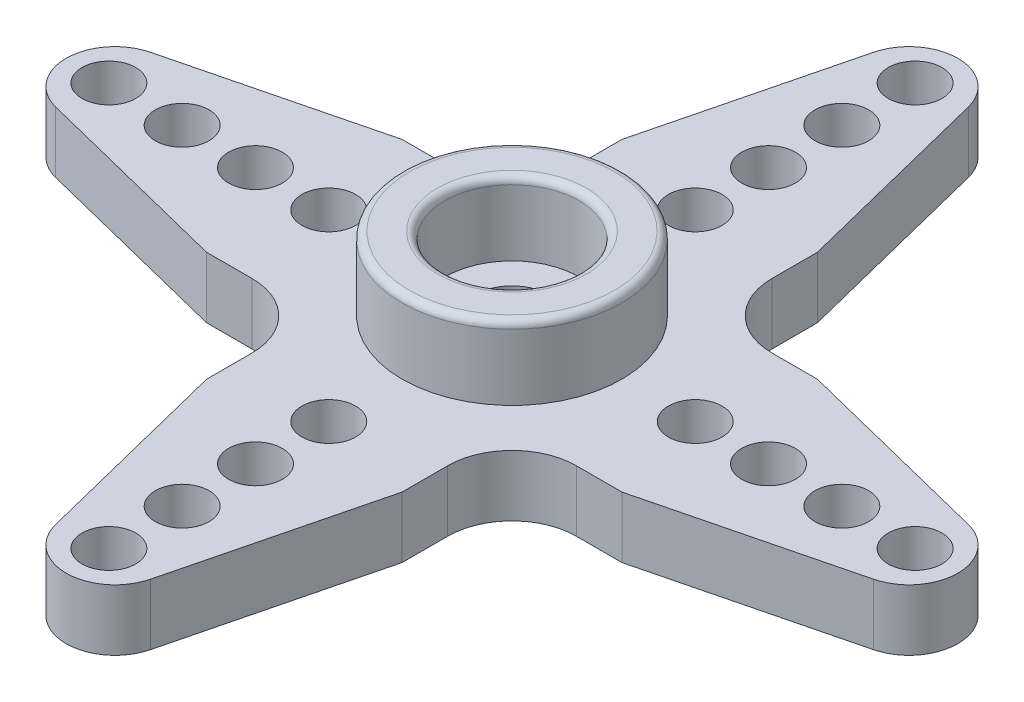
from build123d import *

# Parameters (mm, degrees)
SALIENTE_EXTRUIR1_DEPTH = 2.5
CROQUIS2_R              = 4.5
CROQUIS2_R_2            = 2.75
SALIENTE_EXTRUIR2_DEPTH = 3
CORTAR_EXTRUIR1_REACH   = 7.5
CROQUIS3_R              = 1.5
CROQUIS4_R              = 2.8
CORTAR_EXTRUIR2_DEPTH   = 1
CROQUIS5_R              = 4.5
CROQUIS5_R_2            = 3.5
CORTAR_EXTRUIR3_DEPTH   = 0.5
REDONDEO1_R             = 0.3
CROQUIS6_R              = 1.1
CORTAR_EXTRUIR4_DEPTH   = 2.5
MATRIZC1_COUNT          = 4


with BuildPart() as part:
    # Croquis1 → Saliente-Extruir1 (new body)
    with BuildSketch(Plane(origin=(0, 0, 0), x_dir=(1, 0, 0), z_dir=(0, 1, 0))):
        with BuildLine():
            Line((-8.5, 4), (-6.639087297, 4))
            ThreePointArc((-6.639087297, 4), (-4.772970773, 4.772970773), (-4, 6.639087297))
            Line((-4, 6.639087297), (-4, 8.5))
            Line((-4, 8.5), (-1.940232481, 16.73528128))
            ThreePointArc((-1.940232481, 16.73528128), (0, 18.25), (1.940232481, 16.73528128))
            Line((1.940232481, 16.73528128), (4, 8.5))
            Line((4, 8.5), (4, 6.639087297))
            ThreePointArc((4, 6.639087297), (4.772970773, 4.772970773), (6.639087297, 4))
            Line((6.639087297, 4), (8.5, 4))
            Line((8.5, 4), (16.73528128, 1.940232481))
            ThreePointArc((16.73528128, 1.940232481), (18.25, 0), (16.73528128, -1.940232481))
            Line((16.73528128, -1.940232481), (8.5, -4))
            Line((8.5, -4), (6.639087297, -4))
            ThreePointArc((6.639087297, -4), (4.772970773, -4.772970773), (4, -6.639087297))
            Line((4, -6.639087297), (4, -8.5))
            Line((4, -8.5), (1.940232481, -16.73528128))
            ThreePointArc((1.940232481, -16.73528128), (0, -18.25), (-1.940232481, -16.73528128))
            Line((-1.940232481, -16.73528128), (-4, -8.5))
            Line((-4, -8.5), (-4, -6.639087297))
            ThreePointArc((-4, -6.639087297), (-4.772970773, -4.772970773), (-6.639087297, -4))
            Line((-6.639087297, -4), (-8.5, -4))
            Line((-8.5, -4), (-16.73528128, -1.940232481))
            ThreePointArc((-16.73528128, -1.940232481), (-18.25, 0), (-16.73528128, 1.940232481))
            Line((-16.73528128, 1.940232481), (-8.5, 4))
        make_face()
    extrude(amount=SALIENTE_EXTRUIR1_DEPTH)

    # Croquis2 → Saliente-Extruir2 (add)
    with BuildSketch(Plane(origin=(0, 2.5, 0), x_dir=(1, 0, 0), z_dir=(0, 1, 0))):
        Circle(CROQUIS2_R)
        Circle(CROQUIS2_R_2, mode=Mode.SUBTRACT)
    extrude(amount=SALIENTE_EXTRUIR2_DEPTH)

    # Croquis3 → Cortar-Extruir1 (cut, up to next)
    with BuildSketch(Plane.XZ, mode=Mode.PRIVATE) as cortar_extruir1_sk1:
        Circle(CROQUIS3_R)
    cortar_extruir1_tool1 = extrude(cortar_extruir1_sk1.sketch, amount=-CORTAR_EXTRUIR1_REACH, mode=Mode.PRIVATE) & part.part
    add(cortar_extruir1_tool1.solids().sort_by_distance((0, 0, 0))[0], mode=Mode.SUBTRACT)

    # Croquis4 → Cortar-Extruir2 (cut)
    with BuildSketch(Plane.XZ):
        Circle(CROQUIS4_R)
    extrude(amount=-CORTAR_EXTRUIR2_DEPTH, mode=Mode.SUBTRACT)

    # Croquis5 → Cortar-Extruir3 (cut)
    with BuildSketch(Plane.XZ):
        Circle(CROQUIS5_R)
        Circle(CROQUIS5_R_2, mode=Mode.SUBTRACT)
    extrude(amount=-CORTAR_EXTRUIR3_DEPTH, mode=Mode.SUBTRACT)

    # Redondeo1
    redondeo1_edges = [part.edges().sort_by_distance(p)[0] for p in [
        (-4.5, 5.5, 0),
        (-2.75, 5.5, 0),
        (-2.8, 0, 0),
        (-4.5, 0, 0),
        (-3.5, 0, 0),
    ]]
    fillet(redondeo1_edges, radius=REDONDEO1_R)

    # Croquis6 → Cortar-Extruir4 (cut)
    with BuildSketch(Plane.XZ):
        with Locations((0, -16.5)):
            Circle(CROQUIS6_R)
        with Locations((0, -13.5)):
            Circle(CROQUIS6_R)
        with Locations((0, -10.5)):
            Circle(CROQUIS6_R)
        with Locations((0, -7.5)):
            Circle(CROQUIS6_R)
    cortar_extruir4 = extrude(amount=-CORTAR_EXTRUIR4_DEPTH, mode=Mode.SUBTRACT)

    # MatrizC1: Cortar-Extruir4 ×4 about axis
    matrizc1_axis = Axis((0, 0, 0), (0, 1, 0))
    for i in range(1, MATRIZC1_COUNT):
        add(cortar_extruir4.rotate(matrizc1_axis, i * 360 / MATRIZC1_COUNT), mode=Mode.SUBTRACT)


solid = part.part
